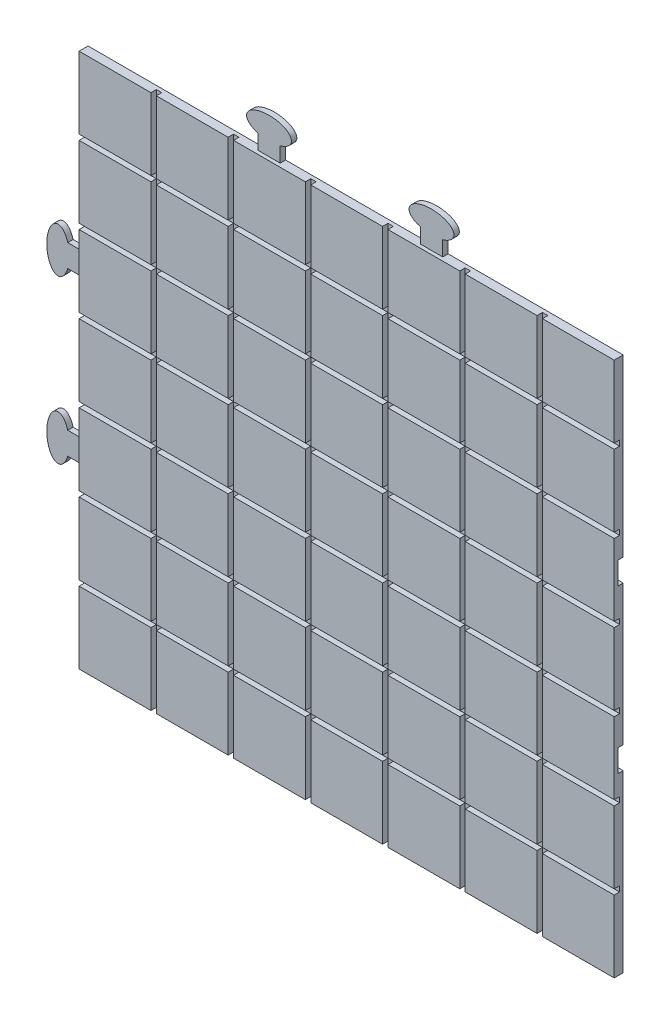
from build123d import *

# Parameters (mm, degrees)
ESQUISSE1_W             = 298
ESQUISSE1_H             = 298
BOSS_EXTRU_1_DEPTH      = 5
ESQUISSE2_W             = 3
ESQUISSE2_H             = 298
ESQUISSE2_W_2           = 298
ESQUISSE2_H_2           = 3
ENL_V_MAT_EXTRU_5_DEPTH = 3
BOSS_EXTRU_2_DEPTH      = 3
ENL_V_MAT_EXTRU_6_DEPTH = 3


with BuildPart() as part:
    # Esquisse1 → Boss.-Extru.1 (new body)
    with BuildSketch(Plane.XY):
        Rectangle(ESQUISSE1_W, ESQUISSE1_H)
    extrude(amount=BOSS_EXTRU_1_DEPTH)

    # Esquisse2 → Enlèv. mat.-Extru.5 (cut)
    with BuildSketch(Plane.XY.offset(5)):
        with Locations((-107.5, 0)):
            Rectangle(ESQUISSE2_W, ESQUISSE2_H)
        with Locations((-64.5, 0)):
            Rectangle(ESQUISSE2_W, ESQUISSE2_H)
        with Locations((-21.5, 0)):
            Rectangle(ESQUISSE2_W, ESQUISSE2_H)
        with Locations((21.5, 0)):
            Rectangle(ESQUISSE2_W, ESQUISSE2_H)
        with Locations((64.5, 0)):
            Rectangle(ESQUISSE2_W, ESQUISSE2_H)
        with Locations((107.5, 0)):
            Rectangle(ESQUISSE2_W, ESQUISSE2_H)
        with Locations((0, 64.5)):
            Rectangle(ESQUISSE2_W_2, ESQUISSE2_H_2)
        with Locations((0, 21.5)):
            Rectangle(ESQUISSE2_W_2, ESQUISSE2_H_2)
        with Locations((0, -21.5)):
            Rectangle(ESQUISSE2_W_2, ESQUISSE2_H_2)
        with Locations((0, -64.5)):
            Rectangle(ESQUISSE2_W_2, ESQUISSE2_H_2)
        with Locations((0, -107.5)):
            Rectangle(ESQUISSE2_W_2, ESQUISSE2_H_2)
        with Locations((0, 107.5)):
            Rectangle(ESQUISSE2_W_2, ESQUISSE2_H_2)
    extrude(amount=-ENL_V_MAT_EXTRU_5_DEPTH, mode=Mode.SUBTRACT)

    # Esquisse4 → Boss.-Extru.2 (add)
    with BuildSketch(Plane(origin=(0, 0, 0), x_dir=(-1, 0, 0), z_dir=(0, 0, -1))):
        with BuildLine():
            add(Edge.make_bspline(
                [(-51.5, 157.337341226), (-45.25, 155.533121635), (-39, 157.337341226)],
                knots=[1.047197551, 1.047197551, 1.047197551, 2.094395102, 2.094395102, 2.094395102], degree=2, weights=[1, 0.866025404, 1]))
            Line((-39, 157.337341226), (-39, 162.75))
            Line((-39, 162.75), (-51.5, 162.75))
            Line((-51.5, 162.75), (-51.5, 157.337341226))
        make_face()
        with BuildLine():
            Line((-39, 162.75), (-39, 157.337341226))
            add(Edge.make_bspline(
                [(-39, 157.337341226), (-20.25, 162.75), (-39, 168.162658774), (-57.75, 173.575317547), (-57.75, 162.75)],
                knots=[2.094395102, 2.094395102, 2.094395102, 4.188790205, 4.188790205, 6.283185307, 6.283185307, 6.283185307], degree=2, weights=[1, 0.5, 1, 0.5, 1]))
            add(Edge.make_bspline(
                [(-57.75, 162.75), (-57.75, 159.141560818), (-51.5, 157.337341226)],
                knots=[0, 0, 0, 1.047197551, 1.047197551, 1.047197551], degree=2, weights=[1, 0.866025404, 1]))
            Line((-51.5, 157.337341226), (-51.5, 162.75))
            Line((-51.5, 162.75), (-39, 162.75))
        make_face()
        with BuildLine():
            Line((-51.5, 149), (-39, 149))
            Line((-39, 149), (-39, 157.337341226))
            add(Edge.make_bspline(
                [(-51.5, 157.337341226), (-45.25, 155.533121635), (-39, 157.337341226)],
                knots=[1.047197551, 1.047197551, 1.047197551, 2.094395102, 2.094395102, 2.094395102], degree=2, weights=[1, 0.866025404, 1]))
            Line((-51.5, 157.337341226), (-51.5, 149))
        make_face()
        with BuildLine():
            Line((39, 149), (51.5, 149))
            Line((51.5, 149), (51.5, 157.337341226))
            add(Edge.make_bspline(
                [(39, 157.337341226), (45.25, 155.533121635), (51.5, 157.337341226)],
                knots=[4.188790205, 4.188790205, 4.188790205, 5.235987756, 5.235987756, 5.235987756], degree=2, weights=[1, 0.866025404, 1]))
            Line((39, 157.337341226), (39, 149))
        make_face()
        with BuildLine():
            add(Edge.make_bspline(
                [(39, 157.337341226), (45.25, 155.533121635), (51.5, 157.337341226)],
                knots=[4.188790205, 4.188790205, 4.188790205, 5.235987756, 5.235987756, 5.235987756], degree=2, weights=[1, 0.866025404, 1]))
            Line((51.5, 157.337341226), (51.5, 162.75))
            Line((51.5, 162.75), (39, 162.75))
            Line((39, 162.75), (39, 157.337341226))
        make_face()
        with BuildLine():
            Line((51.5, 162.75), (51.5, 157.337341226))
            add(Edge.make_bspline(
                [(51.5, 157.337341226), (57.75, 159.141560818), (57.75, 162.75)],
                knots=[5.235987756, 5.235987756, 5.235987756, 6.283185307, 6.283185307, 6.283185307], degree=2, weights=[1, 0.866025404, 1]))
            add(Edge.make_bspline(
                [(57.75, 162.75), (57.75, 173.575317547), (39, 168.162658774), (20.25, 162.75), (39, 157.337341226)],
                knots=[0, 0, 0, 2.094395102, 2.094395102, 4.188790205, 4.188790205, 4.188790205], degree=2, weights=[1, 0.5, 1, 0.5, 1]))
            Line((39, 157.337341226), (39, 162.75))
            Line((39, 162.75), (51.5, 162.75))
        make_face()
        with BuildLine():
            Line((157.337341226, -39), (149, -39))
            Line((149, -39), (149, -51.5))
            Line((149, -51.5), (157.337341226, -51.5))
            add(Edge.make_bspline(
                [(157.337341226, -39), (155.533121635, -45.25), (157.337341226, -51.5)],
                knots=[4.188790205, 4.188790205, 4.188790205, 5.235987756, 5.235987756, 5.235987756], degree=2, weights=[1, 0.866025404, 1]))
        make_face()
        with BuildLine():
            add(Edge.make_bspline(
                [(162.75, -57.75), (173.575317547, -57.75), (168.162658774, -39), (162.75, -20.25), (157.337341226, -39)],
                knots=[0, 0, 0, 2.094395102, 2.094395102, 4.188790205, 4.188790205, 4.188790205], degree=2, weights=[1, 0.5, 1, 0.5, 1]))
            Line((157.337341226, -39), (162.75, -39))
            Line((162.75, -39), (162.75, -51.5))
            Line((162.75, -51.5), (157.337341226, -51.5))
            add(Edge.make_bspline(
                [(157.337341226, -51.5), (159.141560818, -57.75), (162.75, -57.75)],
                knots=[5.235987756, 5.235987756, 5.235987756, 6.283185307, 6.283185307, 6.283185307], degree=2, weights=[1, 0.866025404, 1]))
        make_face()
        with BuildLine():
            Line((162.75, -39), (157.337341226, -39))
            add(Edge.make_bspline(
                [(157.337341226, -39), (155.533121635, -45.25), (157.337341226, -51.5)],
                knots=[4.188790205, 4.188790205, 4.188790205, 5.235987756, 5.235987756, 5.235987756], degree=2, weights=[1, 0.866025404, 1]))
            Line((157.337341226, -51.5), (162.75, -51.5))
            Line((162.75, -51.5), (162.75, -39))
        make_face()
        with BuildLine():
            Line((149, 51.5), (149, 39))
            Line((149, 39), (157.337341226, 39))
            add(Edge.make_bspline(
                [(157.337341226, 51.5), (155.533121635, 45.25), (157.337341226, 39)],
                knots=[1.047197551, 1.047197551, 1.047197551, 2.094395102, 2.094395102, 2.094395102], degree=2, weights=[1, 0.866025404, 1]))
            Line((157.337341226, 51.5), (149, 51.5))
        make_face()
        with BuildLine():
            add(Edge.make_bspline(
                [(157.337341226, 51.5), (155.533121635, 45.25), (157.337341226, 39)],
                knots=[1.047197551, 1.047197551, 1.047197551, 2.094395102, 2.094395102, 2.094395102], degree=2, weights=[1, 0.866025404, 1]))
            Line((157.337341226, 39), (162.75, 39))
            Line((162.75, 39), (162.75, 51.5))
            Line((162.75, 51.5), (157.337341226, 51.5))
        make_face()
        with BuildLine():
            Line((162.75, 39), (157.337341226, 39))
            add(Edge.make_bspline(
                [(157.337341226, 39), (162.75, 20.25), (168.162658774, 39), (173.575317547, 57.75), (162.75, 57.75)],
                knots=[2.094395102, 2.094395102, 2.094395102, 4.188790205, 4.188790205, 6.283185307, 6.283185307, 6.283185307], degree=2, weights=[1, 0.5, 1, 0.5, 1]))
            add(Edge.make_bspline(
                [(162.75, 57.75), (159.141560818, 57.75), (157.337341226, 51.5)],
                knots=[0, 0, 0, 1.047197551, 1.047197551, 1.047197551], degree=2, weights=[1, 0.866025404, 1]))
            Line((157.337341226, 51.5), (162.75, 51.5))
            Line((162.75, 51.5), (162.75, 39))
        make_face()
    extrude(amount=-BOSS_EXTRU_2_DEPTH)

    # Esquisse3 → Enlèv. mat.-Extru.6 (cut)
    with BuildSketch(Plane(origin=(0, 0, 0), x_dir=(-1, 0, 0), z_dir=(0, 0, -1))):
        with BuildLine():
            Line((39, -140.662658774), (39, -149))
            Line((39, -149), (51.5, -149))
            Line((51.5, -149), (51.5, -140.662658774))
            add(Edge.make_bspline(
                [(39, -140.662658774), (45.25, -142.466878365), (51.5, -140.662658774)],
                knots=[4.188790205, 4.188790205, 4.188790205, 5.235987756, 5.235987756, 5.235987756], degree=2, weights=[1, 0.866025404, 1]))
        make_face()
        with BuildLine():
            add(Edge.make_bspline(
                [(57.75, -135.25), (57.75, -124.424682453), (39, -129.837341226), (20.25, -135.25), (39, -140.662658774)],
                knots=[0, 0, 0, 2.094395102, 2.094395102, 4.188790205, 4.188790205, 4.188790205], degree=2, weights=[1, 0.5, 1, 0.5, 1]))
            Line((39, -140.662658774), (39, -135.25))
            Line((39, -135.25), (51.5, -135.25))
            Line((51.5, -135.25), (51.5, -140.662658774))
            add(Edge.make_bspline(
                [(51.5, -140.662658774), (57.75, -138.858439182), (57.75, -135.25)],
                knots=[5.235987756, 5.235987756, 5.235987756, 6.283185307, 6.283185307, 6.283185307], degree=2, weights=[1, 0.866025404, 1]))
        make_face()
        with BuildLine():
            Line((39, -135.25), (39, -140.662658774))
            add(Edge.make_bspline(
                [(39, -140.662658774), (45.25, -142.466878365), (51.5, -140.662658774)],
                knots=[4.188790205, 4.188790205, 4.188790205, 5.235987756, 5.235987756, 5.235987756], degree=2, weights=[1, 0.866025404, 1]))
            Line((51.5, -140.662658774), (51.5, -135.25))
            Line((51.5, -135.25), (39, -135.25))
        make_face()
        with BuildLine():
            add(Edge.make_bspline(
                [(-51.5, -140.662658774), (-45.25, -142.466878365), (-39, -140.662658774)],
                knots=[1.047197551, 1.047197551, 1.047197551, 2.094395102, 2.094395102, 2.094395102], degree=2, weights=[1, 0.866025404, 1]))
            Line((-51.5, -140.662658774), (-51.5, -149))
            Line((-51.5, -149), (-39, -149))
            Line((-39, -149), (-39, -140.662658774))
        make_face()
        with BuildLine():
            Line((-51.5, -140.662658774), (-51.5, -135.25))
            Line((-51.5, -135.25), (-39, -135.25))
            Line((-39, -135.25), (-39, -140.662658774))
            add(Edge.make_bspline(
                [(-39, -140.662658774), (-20.25, -135.25), (-39, -129.837341226), (-57.75, -124.424682453), (-57.75, -135.25)],
                knots=[2.094395102, 2.094395102, 2.094395102, 4.188790205, 4.188790205, 6.283185307, 6.283185307, 6.283185307], degree=2, weights=[1, 0.5, 1, 0.5, 1]))
            add(Edge.make_bspline(
                [(-57.75, -135.25), (-57.75, -138.858439182), (-51.5, -140.662658774)],
                knots=[0, 0, 0, 1.047197551, 1.047197551, 1.047197551], degree=2, weights=[1, 0.866025404, 1]))
        make_face()
        with BuildLine():
            Line((-39, -135.25), (-51.5, -135.25))
            Line((-51.5, -135.25), (-51.5, -140.662658774))
            add(Edge.make_bspline(
                [(-51.5, -140.662658774), (-45.25, -142.466878365), (-39, -140.662658774)],
                knots=[1.047197551, 1.047197551, 1.047197551, 2.094395102, 2.094395102, 2.094395102], degree=2, weights=[1, 0.866025404, 1]))
            Line((-39, -140.662658774), (-39, -135.25))
        make_face()
        with BuildLine():
            Line((-149, -39), (-149, -51.5))
            Line((-149, -51.5), (-140.662658774, -51.5))
            add(Edge.make_bspline(
                [(-140.662658774, -39), (-142.466878365, -45.25), (-140.662658774, -51.5)],
                knots=[4.188790205, 4.188790205, 4.188790205, 5.235987756, 5.235987756, 5.235987756], degree=2, weights=[1, 0.866025404, 1]))
            Line((-140.662658774, -39), (-149, -39))
        make_face()
        with BuildLine():
            add(Edge.make_bspline(
                [(-140.662658774, -39), (-142.466878365, -45.25), (-140.662658774, -51.5)],
                knots=[4.188790205, 4.188790205, 4.188790205, 5.235987756, 5.235987756, 5.235987756], degree=2, weights=[1, 0.866025404, 1]))
            Line((-140.662658774, -51.5), (-135.25, -51.5))
            Line((-135.25, -51.5), (-135.25, -39))
            Line((-135.25, -39), (-140.662658774, -39))
        make_face()
        with BuildLine():
            Line((-135.25, -51.5), (-140.662658774, -51.5))
            add(Edge.make_bspline(
                [(-140.662658774, -51.5), (-138.858439182, -57.75), (-135.25, -57.75)],
                knots=[5.235987756, 5.235987756, 5.235987756, 6.283185307, 6.283185307, 6.283185307], degree=2, weights=[1, 0.866025404, 1]))
            add(Edge.make_bspline(
                [(-135.25, -57.75), (-124.424682453, -57.75), (-129.837341226, -39), (-135.25, -20.25), (-140.662658774, -39)],
                knots=[0, 0, 0, 2.094395102, 2.094395102, 4.188790205, 4.188790205, 4.188790205], degree=2, weights=[1, 0.5, 1, 0.5, 1]))
            Line((-140.662658774, -39), (-135.25, -39))
            Line((-135.25, -39), (-135.25, -51.5))
        make_face()
        with BuildLine():
            Line((-149, 51.5), (-149, 39))
            Line((-149, 39), (-140.662658774, 39))
            add(Edge.make_bspline(
                [(-140.662658774, 51.5), (-142.466878365, 45.25), (-140.662658774, 39)],
                knots=[1.047197551, 1.047197551, 1.047197551, 2.094395102, 2.094395102, 2.094395102], degree=2, weights=[1, 0.866025404, 1]))
            Line((-140.662658774, 51.5), (-149, 51.5))
        make_face()
        with BuildLine():
            add(Edge.make_bspline(
                [(-140.662658774, 51.5), (-142.466878365, 45.25), (-140.662658774, 39)],
                knots=[1.047197551, 1.047197551, 1.047197551, 2.094395102, 2.094395102, 2.094395102], degree=2, weights=[1, 0.866025404, 1]))
            Line((-140.662658774, 39), (-135.25, 39))
            Line((-135.25, 39), (-135.25, 51.5))
            Line((-135.25, 51.5), (-140.662658774, 51.5))
        make_face()
        with BuildLine():
            Line((-135.25, 39), (-140.662658774, 39))
            add(Edge.make_bspline(
                [(-140.662658774, 39), (-135.25, 20.25), (-129.837341226, 39), (-124.424682453, 57.75), (-135.25, 57.75)],
                knots=[2.094395102, 2.094395102, 2.094395102, 4.188790205, 4.188790205, 6.283185307, 6.283185307, 6.283185307], degree=2, weights=[1, 0.5, 1, 0.5, 1]))
            add(Edge.make_bspline(
                [(-135.25, 57.75), (-138.858439182, 57.75), (-140.662658774, 51.5)],
                knots=[0, 0, 0, 1.047197551, 1.047197551, 1.047197551], degree=2, weights=[1, 0.866025404, 1]))
            Line((-140.662658774, 51.5), (-135.25, 51.5))
            Line((-135.25, 51.5), (-135.25, 39))
        make_face()
    extrude(amount=-ENL_V_MAT_EXTRU_6_DEPTH, mode=Mode.SUBTRACT)


solid = part.part
